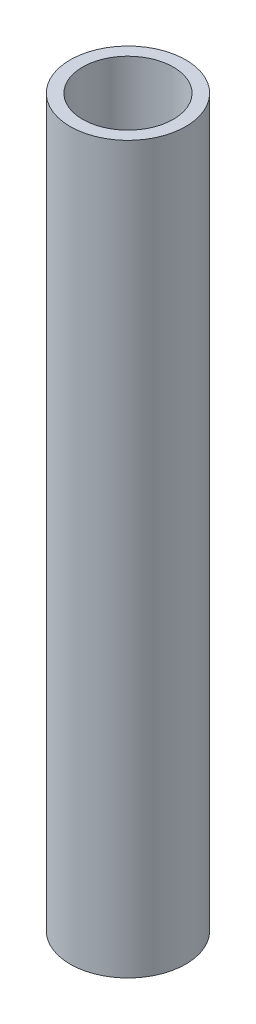
from build123d import *

# Parameters (mm, degrees)
SKETCH1_R           = 24.2824
SKETCH1_R_2         = 19.05
BOSS_EXTRUDE1_DEPTH = 152.4


with BuildPart() as part:
    # Sketch1 → Boss-Extrude1 (new body, symmetric)
    with BuildSketch(Plane(origin=(0, 0, 0), x_dir=(1, 0, 0), z_dir=(0, 1, 0))):
        Circle(SKETCH1_R)
        Circle(SKETCH1_R_2, mode=Mode.SUBTRACT)
    extrude(amount=BOSS_EXTRUDE1_DEPTH, both=True)


solid = part.part
